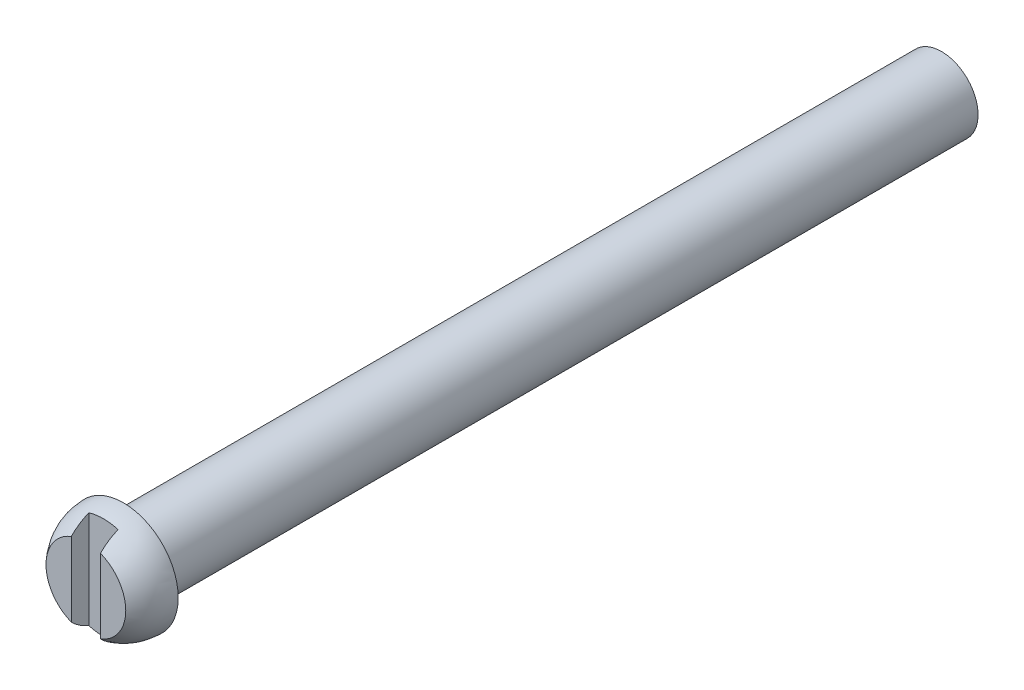
from build123d import *

# Parameters (mm, degrees)
SKETCH1_R               = 3.175
BOSS_EXTRUDE1_DEPTH     = 20.32
REVOLVE1_ANGLE          = 180
CUT_EXTRUDE1_DEPTH      = 8.382
CUT_EXTRUDE1_DEPTH_BACK = 9.398
SKETCH3_W               = 1.756055425
SKETCH3_H               = 11.721669961
SKETCH4_W               = 2.54
SKETCH4_H               = 12.81199514
CUT_EXTRUDE2_DEPTH      = 1.524
BOSS_EXTRUDE2_START     = 50.8
SKETCH5_R               = 3.175
BOSS_EXTRUDE2_DEPTH     = 50.8


with BuildPart() as part:
    # Sketch1 → Boss-Extrude1 (new body)
    with BuildSketch(Plane.XY):
        Circle(SKETCH1_R)
    extrude(amount=BOSS_EXTRUDE1_DEPTH)

    # Sketch2 → Revolve1 (revolve)
    with BuildSketch(Plane.XY.offset(20.32)):
        with BuildLine():
            Line((0, -4.7625), (0, 4.7625))
            ThreePointArc((0, 4.7625), (4.7625, 0), (0, -4.7625))
        make_face()
    revolve(axis=Axis((0, -4.7625, 20.32), (0, -1, 0)), revolution_arc=REVOLVE1_ANGLE)

    # Sketch3 → Cut-Extrude1 (cut, two sides: drawn at the far end of the back side and taken through both)
    with BuildSketch(Plane(origin=(2.54, 0, 0), x_dir=(0, 0, -1), z_dir=(1, 0, 0)).offset(-CUT_EXTRUDE1_DEPTH_BACK)):
        with Locations((-24.463510257, -1.014387128)):
            Rectangle(SKETCH3_W, SKETCH3_H)
    extrude(amount=CUT_EXTRUDE1_DEPTH + CUT_EXTRUDE1_DEPTH_BACK, mode=Mode.SUBTRACT)

    # Sketch4 → Cut-Extrude2 (cut)
    with BuildSketch(Plane.XY.offset(23.585482544)):
        with Locations((0, -0.792879604)):
            Rectangle(SKETCH4_W, SKETCH4_H)
    extrude(amount=-CUT_EXTRUDE2_DEPTH, mode=Mode.SUBTRACT)

    # Sketch5 → Boss-Extrude2 (add)
    with BuildSketch(Plane(origin=(0, 0, 0), x_dir=(-1, 0, 0), z_dir=(0, 0, -1)).offset(BOSS_EXTRUDE2_START)):
        Circle(SKETCH5_R)
    extrude(amount=-BOSS_EXTRUDE2_DEPTH)


solid = part.part
